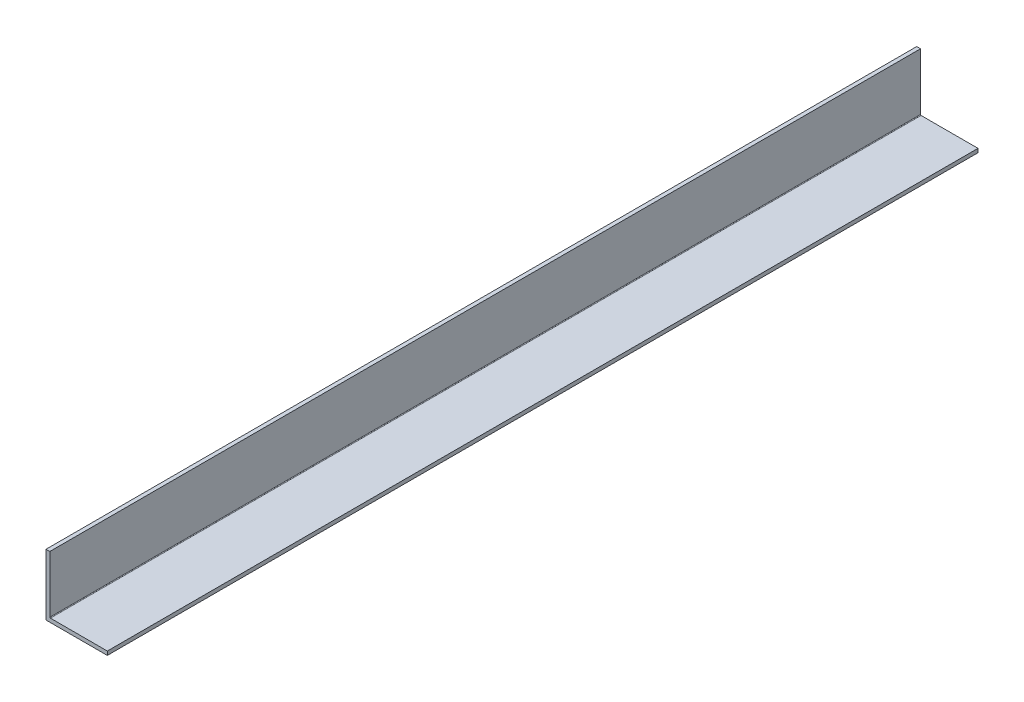
from build123d import *

# Parameters (mm, degrees)
BOSS_EXTRUDE1_DEPTH = 304.8
FILLET1_R           = 0.254
CUT_EXTRUDE1_DEPTH  = 248.9375


with BuildPart() as part:
    # Sketch3 → Boss-Extrude1 (new, symmetric)
    with BuildSketch(Plane.XY):
        Polygon((1.5875, 25.4), (0, 25.4), (0, 0), (25.4, 0), (25.4, 1.5875), (1.5875, 1.5875), align=None)
    extrude(amount=BOSS_EXTRUDE1_DEPTH, both=True)

    # Fillet1
    fillet1_edges = [part.edges().sort_by_distance(p)[0] for p in [
        (1.5875, 1.5875, 0),
    ]]
    fillet(fillet1_edges, radius=FILLET1_R)

    # Sketch4 → Cut-Extrude1 (cut)
    with BuildSketch(Plane(origin=(0, 0, -304.8), x_dir=(-1, 0, 0), z_dir=(0, 0, -1))):
        with BuildLine():
            Line((-1.5875, 25.4), (-1.5875, 1.8415))
            ThreePointArc((-1.5875, 1.8415), (-1.661894878, 1.661894878), (-1.8415, 1.5875))
            Line((-1.8415, 1.5875), (-25.4, 1.5875))
            Line((-25.4, 1.5875), (-25.4, 0))
            Line((-25.4, 0), (0, 0))
            Line((0, 0), (0, 25.4))
            Line((0, 25.4), (-1.5875, 25.4))
        make_face()
    extrude(amount=-CUT_EXTRUDE1_DEPTH, mode=Mode.SUBTRACT)


solid = part.part
